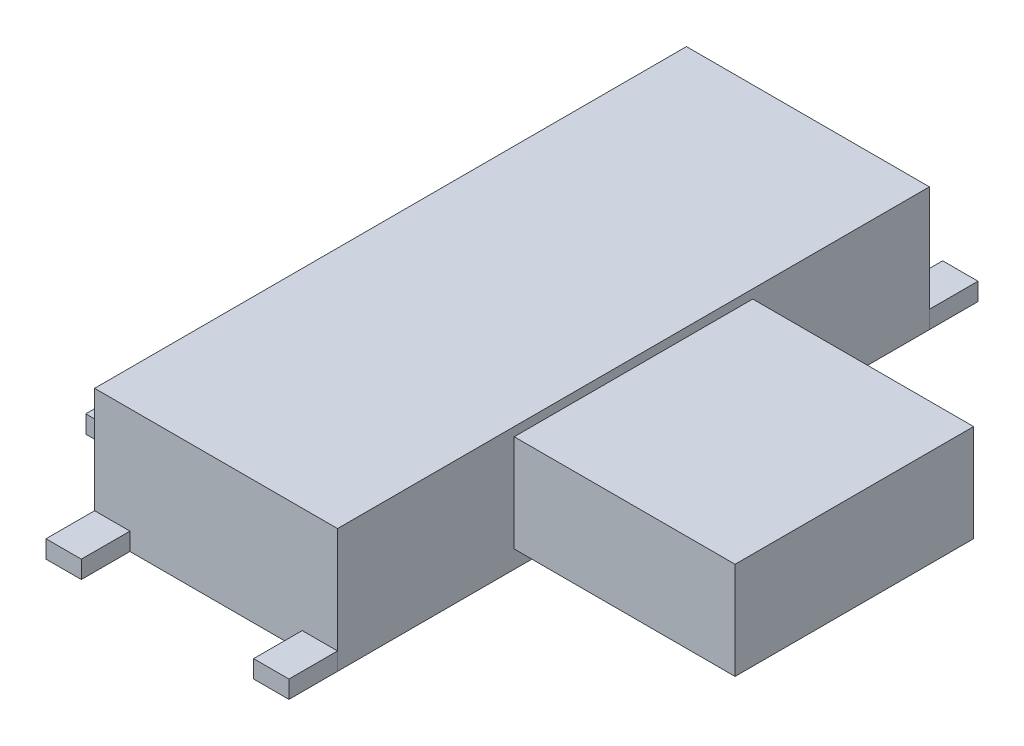
from build123d import *

# Parameters (mm, degrees)
SKETCH_1_W        = 2.75
SKETCH_1_H        = 6.7
EXTRUDE_1_DEPTH   = 1.4
SKETCH_2_R        = 0.35
EXTRUDE_2_DEPTH   = 0.5
SKETCH_4_W        = 1
SKETCH_4_H        = 0.4
EXTRUDE_4_DEPTH   = 0.2
EXTRUDE_4_2_DEPTH = 0.2
EXTRUDE_4_3_DEPTH = 0.2
SKETCH_4_W_2      = 0.4
SKETCH_4_H_2      = 0.55
EXTRUDE_4_4_DEPTH = 0.2
EXTRUDE_4_5_DEPTH = 0.2
EXTRUDE_4_6_DEPTH = 0.2
EXTRUDE_4_7_DEPTH = 0.2
SKETCH_3_W        = 1.6
SKETCH_3_H        = 1.1
EXTRUDE_3_DEPTH   = 2.5


with BuildPart() as part:
    # 草图1 → 凸台-拉伸1 (new body)
    with BuildSketch(Plane(origin=(0, 0, 0), x_dir=(1, 0, 0), z_dir=(0, 1, 0))):
        Rectangle(SKETCH_1_W, SKETCH_1_H)
    extrude(amount=EXTRUDE_1_DEPTH)

    # 草图2 → 凸台-拉伸2 (add)
    with BuildSketch(Plane.XZ):
        with Locations((0, 1.5)):
            Circle(SKETCH_2_R)
        with Locations((0, -1.5)):
            Circle(SKETCH_2_R)
    extrude(amount=EXTRUDE_2_DEPTH)

    # 草图3 → 凸台-拉伸3 (add)
    with BuildSketch(Plane(origin=(1.375, 0, 0), x_dir=(0, 0, -1), z_dir=(1, 0, 0))):
        with Locations((0.55, 0.75)):
            Rectangle(SKETCH_3_W, SKETCH_3_H)
    extrude_3 = extrude(amount=EXTRUDE_3_DEPTH)

    # 镜向1: 凸台-拉伸3 across plane
    add(extrude_3.mirror(Plane.XY))


with BuildPart() as body_2:
    # 草图4 → 凸台-拉伸4 (new body)
    with BuildSketch(Plane(origin=(0, 0, 0), x_dir=(1, 0, 0), z_dir=(0, 1, 0))):
        with Locations((-1.875, 2.25)):
            Rectangle(SKETCH_4_W, SKETCH_4_H)
    extrude(amount=EXTRUDE_4_DEPTH)


with BuildPart() as body_3:
    # 草图4 → Extrude 4 2 (new body)
    with BuildSketch(Plane(origin=(0, 0, 0), x_dir=(1, 0, 0), z_dir=(0, 1, 0))):
        with Locations((-1.875, -2.25)):
            Rectangle(SKETCH_4_W, SKETCH_4_H)
    extrude(amount=EXTRUDE_4_2_DEPTH)


with BuildPart() as body_4:
    # 草图4 → Extrude 4 3 (new body)
    with BuildSketch(Plane(origin=(0, 0, 0), x_dir=(1, 0, 0), z_dir=(0, 1, 0))):
        with Locations((-1.875, 0.75)):
            Rectangle(SKETCH_4_W, SKETCH_4_H)
    extrude(amount=EXTRUDE_4_3_DEPTH)


with BuildPart() as body_5:
    # 草图4 → Extrude 4 4 (new body)
    with BuildSketch(Plane(origin=(0, 0, 0), x_dir=(1, 0, 0), z_dir=(0, 1, 0))):
        with Locations((-1.175, 3.625)):
            Rectangle(SKETCH_4_W_2, SKETCH_4_H_2)
    extrude(amount=EXTRUDE_4_4_DEPTH)


with BuildPart() as body_6:
    # 草图4 → Extrude 4 5 (new body)
    with BuildSketch(Plane(origin=(0, 0, 0), x_dir=(1, 0, 0), z_dir=(0, 1, 0))):
        with Locations((1.175, 3.625)):
            Rectangle(SKETCH_4_W_2, SKETCH_4_H_2)
    extrude(amount=EXTRUDE_4_5_DEPTH)


with BuildPart() as body_7:
    # 草图4 → Extrude 4 6 (new body)
    with BuildSketch(Plane(origin=(0, 0, 0), x_dir=(1, 0, 0), z_dir=(0, 1, 0))):
        with Locations((-1.175, -3.625)):
            Rectangle(SKETCH_4_W_2, SKETCH_4_H_2)
    extrude(amount=EXTRUDE_4_6_DEPTH)


with BuildPart() as body_8:
    # 草图4 → Extrude 4 7 (new body)
    with BuildSketch(Plane(origin=(0, 0, 0), x_dir=(1, 0, 0), z_dir=(0, 1, 0))):
        with Locations((1.175, -3.625)):
            Rectangle(SKETCH_4_W_2, SKETCH_4_H_2)
    extrude(amount=EXTRUDE_4_7_DEPTH)


solid = Compound([part.part, body_2.part, body_3.part, body_4.part, body_5.part, body_6.part, body_7.part, body_8.part])
